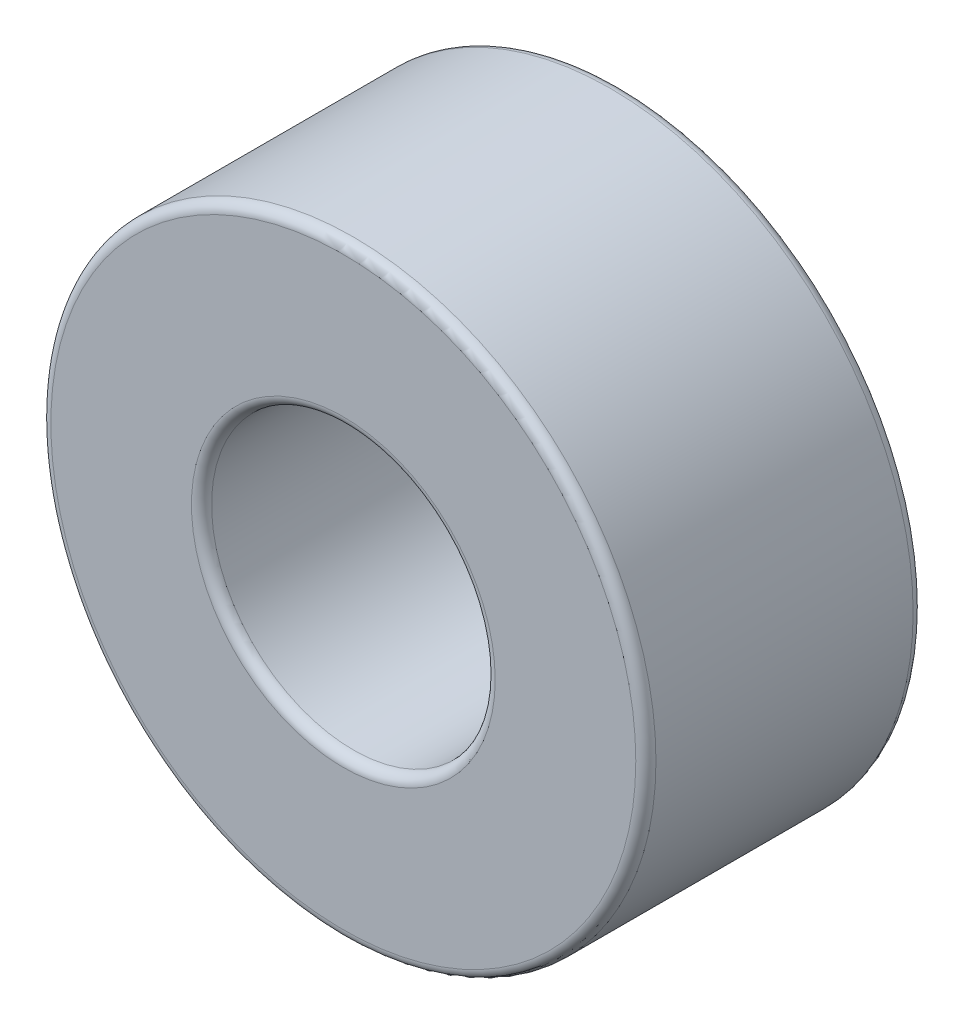
from build123d import *

# Parameters (mm, degrees)
SKETCH1_R           = 24
SKETCH1_R_2         = 11.25
BOSS_EXTRUDE1_DEPTH = 11
FILLET2_R           = 0.8


with BuildPart() as part:
    # Sketch1 → Boss-Extrude1 (new body, symmetric)
    with BuildSketch(Plane.XY):
        Circle(SKETCH1_R)
        Circle(SKETCH1_R_2, mode=Mode.SUBTRACT)
    extrude(amount=BOSS_EXTRUDE1_DEPTH, both=True)

    # Fillet2
    fillet2_edges = [part.edges().sort_by_distance(p)[0] for p in [
        (-24, 0, -11),
        (-24, 0, 11),
        (-11.25, 0, -11),
        (-11.25, 0, 11),
    ]]
    fillet(fillet2_edges, radius=FILLET2_R)


solid = part.part
